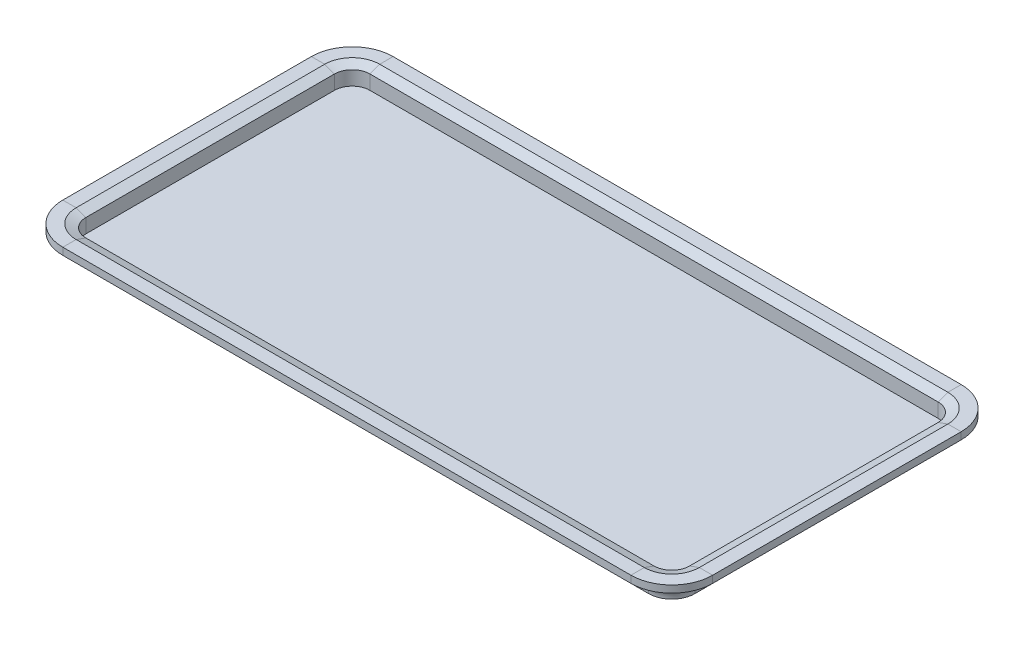
from build123d import *

# Parameters (mm, degrees)
EXTRUDE_1_DEPTH = 20


with BuildPart() as part:
    # 草图1 → 凸台-拉伸1 (new body)
    with BuildSketch(Plane(origin=(0, 0, 0), x_dir=(1, 0, 0), z_dir=(0, 1, 0))):
        with BuildLine():
            Line((-800, 400), (800, 400))
            ThreePointArc((800, 400), (835.355339059, 385.355339059), (850, 350))
            Line((850, 350), (850, -350))
            ThreePointArc((850, -350), (835.355339059, -385.355339059), (800, -400))
            Line((800, -400), (-800, -400))
            ThreePointArc((-800, -400), (-835.355339059, -385.355339059), (-850, -350))
            Line((-850, -350), (-850, 350))
            ThreePointArc((-850, 350), (-835.355339059, 385.355339059), (-800, 400))
        make_face()
    extrude(amount=EXTRUDE_1_DEPTH)

    # 扫描1: sweep along a path in 草图4
    with BuildLine(Plane(origin=(0, 20, 0), x_dir=(1, 0, 0), z_dir=(0, 1, 0))) as sweep_1_path:
        Line((800, 400), (-800, 400))
        ThreePointArc((-800, 400), (-835.355339059, 385.355339059), (-850, 350))
        Line((-850, 350), (-850, -350))
        ThreePointArc((-850, -350), (-835.355339059, -385.355339059), (-800, -400))
        Line((-800, -400), (800, -400))
        ThreePointArc((800, -400), (835.355339059, -385.355339059), (850, -350))
        Line((850, -350), (850, 350))
        ThreePointArc((850, 350), (835.355339059, 385.355339059), (800, 400))
    # 草图3 → 扫描1 (sweep)
    with BuildSketch(Plane(origin=(0, 0, 350), x_dir=(0, -1, 0), z_dir=(0, 0, 1))):
        with BuildLine():
            Line((0, 850), (-60, 850))
            Line((-60, 850), (-70, 877.474774195))
            Line((-70, 877.474774195), (-70, 915))
            Line((-70, 915), (-50, 915))
            ThreePointArc((-50, 915), (-35.355339059, 879.644660941), (0, 865))
            Line((0, 865), (0, 850))
        make_face()
    sweep(path=sweep_1_path.line)


solid = part.part
